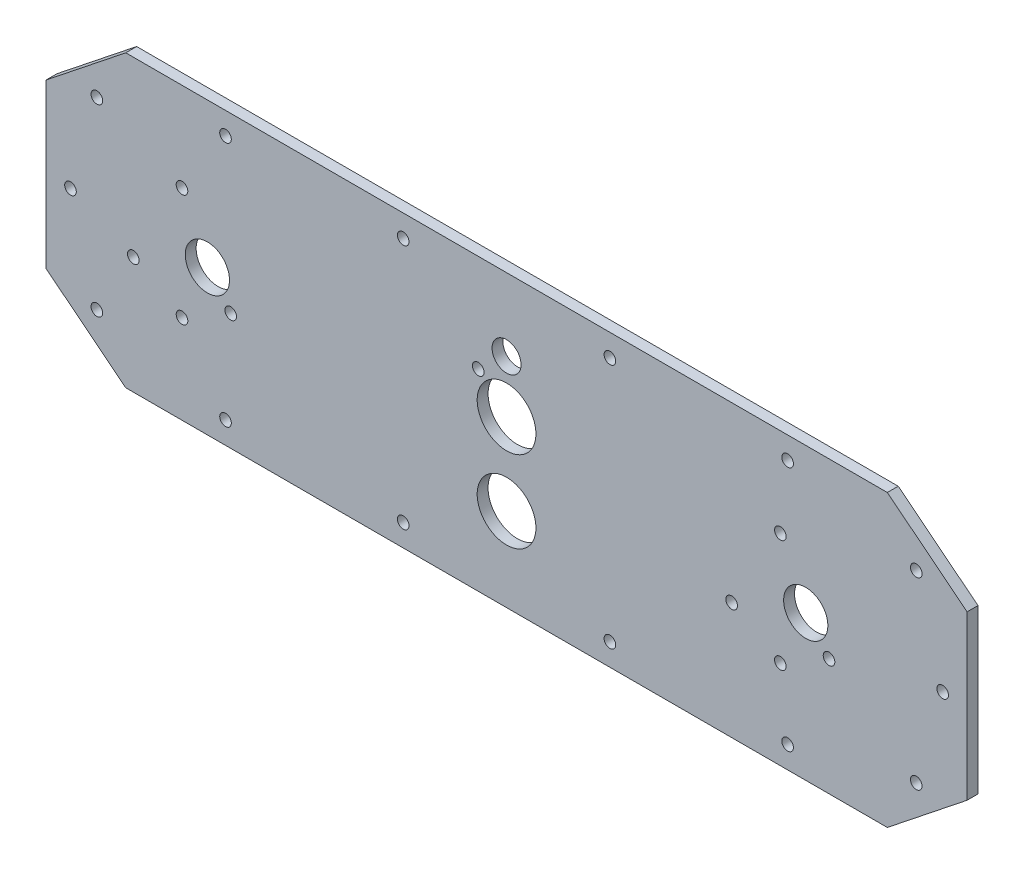
from build123d import *

# Parameters (mm, degrees)
CROQUIS1_R              = 4
CROQUIS1_R_2            = 1.6
CROQUIS1_R_3            = 6.1
CROQUIS1_R_4            = 8.1
SALIENTE_EXTRUIR1_DEPTH = 3


with BuildPart() as part:
    # Croquis1 → Saliente-Extruir1 (new body)
    with BuildSketch(Plane.XY):
        Polygon((-127, 22.5), (-105, 40), (105, 40), (127, 22.5), (127, -22.5), (105, -40), (-105, -40), (-127, -22.5), align=None)
        with Locations((0, 20)):
            Circle(CROQUIS1_R, mode=Mode.SUBTRACT)
        with Locations((112.98, 25.35)):
            Circle(CROQUIS1_R_2, mode=Mode.SUBTRACT)
        with Locations((120.25, 0)):
            Circle(CROQUIS1_R_2, mode=Mode.SUBTRACT)
        with Locations((112.98, -25.35)):
            Circle(CROQUIS1_R_2, mode=Mode.SUBTRACT)
        with Locations((77.5, -33.9)):
            Circle(CROQUIS1_R_2, mode=Mode.SUBTRACT)
        with Locations((28.5, -33.9)):
            Circle(CROQUIS1_R_2, mode=Mode.SUBTRACT)
        with Locations((-28.5, -33.9)):
            Circle(CROQUIS1_R_2, mode=Mode.SUBTRACT)
        with Locations((-77.5, -33.9)):
            Circle(CROQUIS1_R_2, mode=Mode.SUBTRACT)
        with Locations((-112.98, -25.35)):
            Circle(CROQUIS1_R_2, mode=Mode.SUBTRACT)
        with Locations((-120.25, 0)):
            Circle(CROQUIS1_R_2, mode=Mode.SUBTRACT)
        with Locations((-112.98, 25.35)):
            Circle(CROQUIS1_R_2, mode=Mode.SUBTRACT)
        with Locations((-77.5, 33.9)):
            Circle(CROQUIS1_R_2, mode=Mode.SUBTRACT)
        with Locations((-28.5, 33.9)):
            Circle(CROQUIS1_R_2, mode=Mode.SUBTRACT)
        with Locations((28.5, 33.9)):
            Circle(CROQUIS1_R_2, mode=Mode.SUBTRACT)
        with Locations((77.5, 33.9)):
            Circle(CROQUIS1_R_2, mode=Mode.SUBTRACT)
        with Locations((-82.5, 0)):
            Circle(CROQUIS1_R_3, mode=Mode.SUBTRACT)
        with Locations((82.5, 0)):
            Circle(CROQUIS1_R_3, mode=Mode.SUBTRACT)
        with Locations((0, 5.55)):
            Circle(CROQUIS1_R_4, mode=Mode.SUBTRACT)
        with Locations((0, -16.95)):
            Circle(CROQUIS1_R_4, mode=Mode.SUBTRACT)
        with Locations((-7.8, 13.1)):
            Circle(CROQUIS1_R_2, mode=Mode.SUBTRACT)
        with Locations((75.5, 15.5)):
            Circle(CROQUIS1_R_2, mode=Mode.SUBTRACT)
        with Locations((75.5, -15.5)):
            Circle(CROQUIS1_R_2, mode=Mode.SUBTRACT)
        with Locations((62.076606241, -7.75)):
            Circle(CROQUIS1_R_2, mode=Mode.SUBTRACT)
        with Locations((88.923393759, -7.75)):
            Circle(CROQUIS1_R_2, mode=Mode.SUBTRACT)
        with Locations((-89.5, 15.5)):
            Circle(CROQUIS1_R_2, mode=Mode.SUBTRACT)
        with Locations((-102.923393759, -7.75)):
            Circle(CROQUIS1_R_2, mode=Mode.SUBTRACT)
        with Locations((-76.076606241, -7.75)):
            Circle(CROQUIS1_R_2, mode=Mode.SUBTRACT)
        with Locations((-89.5, -15.5)):
            Circle(CROQUIS1_R_2, mode=Mode.SUBTRACT)
    extrude(amount=SALIENTE_EXTRUIR1_DEPTH)


solid = part.part
